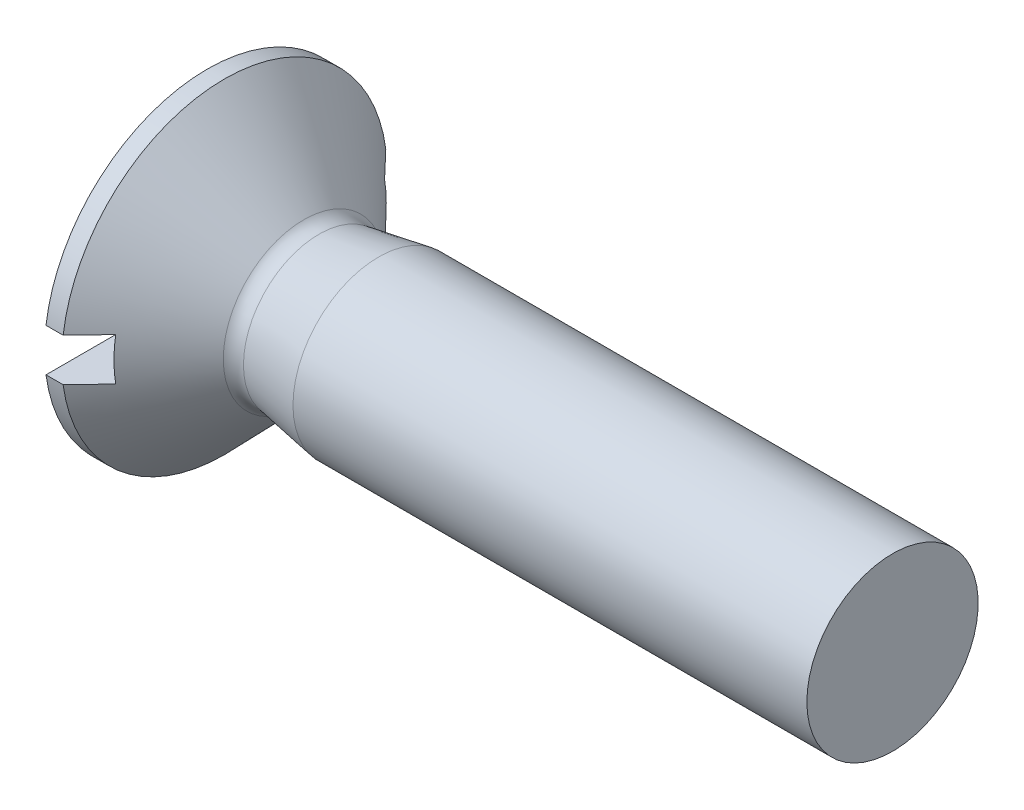
from build123d import *

# Parameters (mm, degrees)
SKETCH_3_W               = 0.5
SKETCH_3_H               = 0.5
CUT_EXTRUDE_1_DEPTH      = 2.9
CUT_EXTRUDE_1_DEPTH_BACK = 2.9


with BuildPart() as part:
    # Эскиз2 → Повернуть1 (revolve)
    with BuildSketch(Plane.XY):
        with BuildLine():
            Line((0, 0), (0, 1.9))
            Line((0, 1.9), (0.2, 1.9))
            Line((0.2, 1.9), (1.126725855, 0.940347284))
            ThreePointArc((1.126725855, 0.940347284), (1.20815228, 0.889276183), (1.304000388, 0.882088693))
            Line((1.304000388, 0.882088693), (2, 1))
            Line((2, 1), (8, 1))
            Line((8, 1), (8, 0))
            Line((8, 0), (0, 0))
        make_face()
    revolve(axis=Axis((0, 0, 0), (1, 0, 0)))

    # Эскиз3 → Вырез-Вытянуть1 (cut, two sides)
    with BuildSketch(Plane.XY) as cut_extrude_1_sk:
        with Locations((0.25, 0)):
            Rectangle(SKETCH_3_W, SKETCH_3_H)
    extrude(amount=CUT_EXTRUDE_1_DEPTH, mode=Mode.SUBTRACT)
    extrude(cut_extrude_1_sk.sketch, amount=-CUT_EXTRUDE_1_DEPTH_BACK, mode=Mode.SUBTRACT)


solid = part.part
